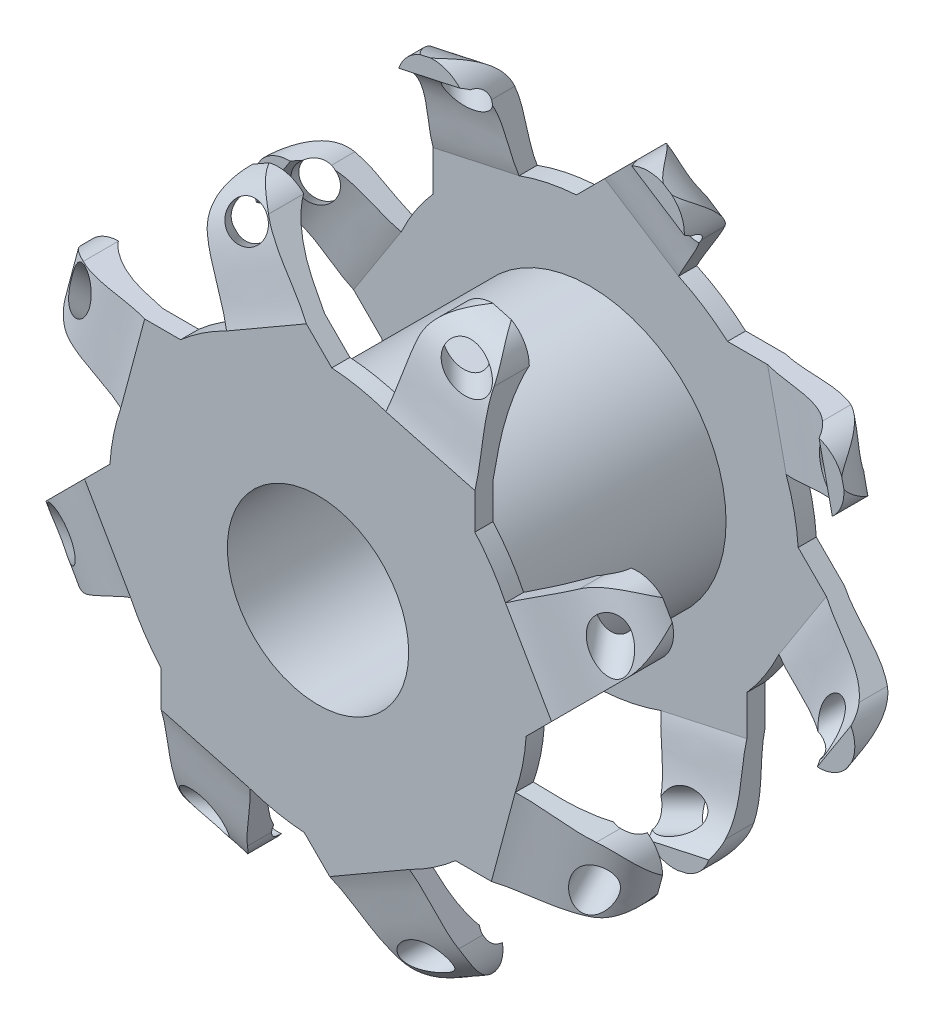
from build123d import *

# Parameters (mm, degrees)
SKETCH1_R               = 15
SS_EXTRUDE1_DEPTH       = 30
SKETCH2_R               = 23
BOSS_EXTRUDE2_DEPTH     = 2
SKETCH3_R               = 23
BOSS_EXTRUDE3_DEPTH     = 2
BOSS_EXTRUDE4_DEPTH     = 6
BOSS_EXTRUDE5_DEPTH     = 6
CUT_EXTRUDE1_START      = -28.577164943
SKETCH8_R               = 2
CUT_EXTRUDE1_DEPTH      = 57.154335489
CUT_EXTRUDE4_DEPTH      = 15
CUT_EXTRUDE5_DEPTH      = 15
CIRPATTERN6_COUNT       = 8
CIRPATTERN7_COUNT       = 8
SKETCH11_R              = 10
CUT_EXTRUDE6_DEPTH      = 3.0000001
CUT_EXTRUDE6_DEPTH_BACK = 31.0000001


with BuildPart() as part:
    # Sketch1 → ss-Extrude1 (new body)
    with BuildSketch(Plane.XY):
        Circle(SKETCH1_R)
    ss_extrude1 = extrude(amount=-SS_EXTRUDE1_DEPTH)

    # Sketch2 → Boss-Extrude2 (add)
    with BuildSketch(Plane.XY):
        Circle(SKETCH2_R)
    boss_extrude2 = extrude(amount=BOSS_EXTRUDE2_DEPTH)

    # Sketch3 → Boss-Extrude3 (add)
    with BuildSketch(Plane(origin=(0, 0, -30), x_dir=(-1, 0, 0), z_dir=(0, 0, -1))):
        Circle(SKETCH3_R)
    extrude(amount=-BOSS_EXTRUDE3_DEPTH)

    # Sketch5 → Boss-Extrude4 (add)
    with BuildSketch(Plane.XY.offset(2)):
        with BuildLine():
            Line((15.154691773, -17.301309698), (28, -17.301309698))
            ThreePointArc((28, -17.301309698), (31.965827804, -13.823047014), (29.034560176, -9.437414611))
            Line((29.034560176, -9.437414611), (21.747532764, -7.486308748))
            ThreePointArc((21.747532764, -7.486308748), (19.092592932, -12.824698638), (15.154691773, -17.301309698))
        make_face()
    boss_extrude4 = extrude(amount=-BOSS_EXTRUDE4_DEPTH)

    # Sketch6 → Boss-Extrude5 (add)
    with BuildSketch(Plane(origin=(0, 0, -30), x_dir=(-1, 0, 0), z_dir=(0, 0, -1))):
        with BuildLine():
            Line((-15.160590445, 17.296141112), (-28, 17.296141112))
            ThreePointArc((-28, 17.296141112), (-31.977210392, 13.722518293), (-28.847895877, 9.387039862))
            Line((-28.847895877, 9.387039862), (-21.629312345, 7.821307274))
            ThreePointArc((-21.629312345, 7.821307274), (-18.995192968, 12.968525133), (-15.160590445, 17.296141112))
        make_face()
    boss_extrude5 = extrude(amount=-BOSS_EXTRUDE5_DEPTH)

    # Sketch8 → Cut-Extrude1 (cut)
    with BuildSketch(Plane(origin=(-1.18e-06, 6.99999764, -6.99999764), x_dir=(0, 0.707106781, 0.707106781), z_dir=(-1.19e-07, 0.707106781, -0.707106781)).offset(CUT_EXTRUDE1_START)):
        with Locations((-10.186742756, 28.331250457)):
            Circle(SKETCH8_R)
    cut_extrude1 = extrude(amount=CUT_EXTRUDE1_DEPTH, mode=Mode.SUBTRACT)

    # Sketch10 → Cut-Extrude4 (cut)
    with BuildSketch(Plane(origin=(-0.648368875, 2.989210877, 0), x_dir=(0.977275312, 0.211973969, 0), z_dir=(0.211973969, -0.977275312, 0))):
        with BuildLine():
            add(Edge.make_bspline(
                [(29.687736426, -26.51649887), (30.951551899, -25.932842362), (31.9870619, -24.948203927), (32.548537045, -23.138080541)],
                knots=[0.618217564, 0.618217564, 0.618217564, 0.618217564, 1, 1, 1, 1], degree=3))
            Line((32.548537045, -23.138080541), (18.65828282, -21.431742028))
            Line((18.65828282, -21.431742028), (17.229503571, -28))
            Line((17.229503571, -28), (22.795706529, -28))
            Line((22.795706529, -28), (22.795706529, -24))
            Line((22.795706529, -24), (27.67778753, -24))
            add(Edge.make_bspline(
                [(27.67778753, -24), (28.093568101, -26.21545958), (29.687736426, -26.51649887)],
                knots=[4.678580772, 4.678580772, 4.678580772, 5.987140113, 5.987140113, 5.987140113], degree=2, weights=[1, 0.75635755, 0.919307532]))
        make_face()
        with BuildLine():
            add(Edge.make_bspline(
                [(22.795706529, -28), (24.996119838, -27.355302034), (27.641249081, -27.461609672), (29.687736426, -26.51649887)],
                knots=[0, 0, 0, 0, 0.618217564, 0.618217564, 0.618217564, 0.618217564], degree=3))
            add(Edge.make_bspline(
                [(27.67778753, -24), (28.093568101, -26.21545958), (29.687736426, -26.51649887)],
                knots=[4.678580772, 4.678580772, 4.678580772, 5.987140113, 5.987140113, 5.987140113], degree=2, weights=[1, 0.75635755, 0.919307532]))
            Line((27.67778753, -24), (22.795706529, -24))
            Line((22.795706529, -24), (22.795706529, -28))
        make_face()
        with BuildLine():
            Line((30.182144557, -30), (30.182144557, -29.090655753))
            add(Edge.make_bspline(
                [(22.795706529, -30), (24.942526902, -29.407717363), (27.910746032, -29.793059948), (30.182144557, -29.090655753)],
                knots=[0, 0, 0, 0, 0.362211893, 0.362211893, 0.362211893, 0.362211893], degree=3))
            Line((22.795706529, -30), (30.182144557, -30))
        make_face()
        with BuildLine():
            add(Edge.make_bspline(
                [(30.182144557, -29.090655753), (30.704087287, -28.929250892), (34.421654826, -27.252327179), (34.897089836, -20.731395195), (34.306434782, -17.906164416)],
                knots=[0.362211893, 0.362211893, 0.362211893, 0.362211893, 0.445444255, 1, 1, 1, 1], degree=3))
            Line((30.182144557, -29.090655753), (30.182144557, -30))
            Line((30.182144557, -30), (22.795706529, -30))
            Line((22.795706529, -30), (17.943893195, -31.941513247))
            Line((17.943893195, -31.941513247), (39.342314041, -33.384330833))
            Line((39.342314041, -33.384330833), (34.306434782, -17.906164416))
        make_face()
    cut_extrude4 = extrude(amount=-CUT_EXTRUDE4_DEPTH, mode=Mode.SUBTRACT)

    # Sketch9 → Cut-Extrude5 (cut)
    with BuildSketch(Plane(origin=(-0.415581547, -1.552121891, 0), x_dir=(0.965973772, -0.258640044, 0), z_dir=(0.258640044, 0.965973772, 0))):
        with BuildLine():
            Line((22.943805474, 4), (22.943805474, 0))
            add(Edge.make_bspline(
                [(22.943805474, 0), (25.095603016, 0.473390819), (27.33894008, 0.923338275), (29.492505686, 2.230659051), (29.678710062, 2.351728443)],
                knots=[0, 0, 0, 0, 0.412137313, 0.451949852, 0.451949852, 0.451949852, 0.451949852], degree=3))
            add(Edge.make_bspline(
                [(28.051525149, 4), (28.639448549, 2.675918332), (29.678710062, 2.351728443)],
                knots=[1.809599306, 1.809599306, 1.809599306, 2.732269736, 2.732269736, 2.732269736], degree=2, weights=[1, 0.852242244, 0.909593483]))
            Line((28.051525149, 4), (22.943805474, 4))
        make_face()
        with BuildLine():
            Line((16.436354412, 0), (22.943805474, 0))
            Line((22.943805474, 0), (22.943805474, 4))
            Line((22.943805474, 4), (28.051525149, 4))
            add(Edge.make_bspline(
                [(28.051525149, 4), (28.639448549, 2.675918332), (29.678710062, 2.351728443)],
                knots=[1.809599306, 1.809599306, 1.809599306, 2.732269736, 2.732269736, 2.732269736], degree=2, weights=[1, 0.852242244, 0.909593483]))
            add(Edge.make_bspline(
                [(29.678710062, 2.351728443), (32.241956104, 4.018341483), (34.141104489, 6.804253018), (28.051525149, 8.762231078)],
                knots=[0.451949852, 0.451949852, 0.451949852, 0.451949852, 1, 1, 1, 1], degree=3))
            Line((28.051525149, 8.762231078), (16.436354412, 6.621068085))
            Line((16.436354412, 6.621068085), (16.436354412, 0))
        make_face()
        with BuildLine():
            add(Edge.make_bspline(
                [(30.487516933, -0.344378274), (32.468941046, 0.375096936), (34.029601794, 1.643169567), (34.391975221, 4.302512453)],
                knots=[0.543111159, 0.543111159, 0.543111159, 0.543111159, 1, 1, 1, 1], degree=3))
            Line((30.487516933, -0.344378274), (30.487516933, -2))
            Line((30.487516933, -2), (22.943805474, -2))
            Line((22.943805474, -2), (19.122740988, -3.480079447))
            Line((19.122740988, -3.480079447), (38.157525495, -7.647167073))
            Line((38.157525495, -7.647167073), (40.071880454, 2.350225744))
            Line((40.071880454, 2.350225744), (35.070824823, 7.847688917))
            Line((35.070824823, 7.847688917), (34.391975221, 4.302512453))
        make_face()
        with BuildLine():
            Line((30.487516933, -2), (30.487516933, -0.344378274))
            add(Edge.make_bspline(
                [(22.943805474, -2), (25.182257071, -1.279688443), (28.13216603, -1.199630098), (30.487516933, -0.344378274)],
                knots=[0, 0, 0, 0, 0.543111159, 0.543111159, 0.543111159, 0.543111159], degree=3))
            Line((22.943805474, -2), (30.487516933, -2))
        make_face()
    cut_extrude5 = extrude(amount=-CUT_EXTRUDE5_DEPTH, mode=Mode.SUBTRACT)

    # CirPattern6: Boss-Extrude2, Boss-Extrude4, Cut-Extrude1, Cut-Extrude5 ×8 about axis
    cirpattern6_axis = Axis((0, 0, 0), (0, 0, -1))
    for i in range(1, CIRPATTERN6_COUNT):
        add(boss_extrude2.rotate(cirpattern6_axis, i * 360 / CIRPATTERN6_COUNT))
        add(boss_extrude4.rotate(cirpattern6_axis, i * 360 / CIRPATTERN6_COUNT))
        add(cut_extrude1.rotate(cirpattern6_axis, i * 360 / CIRPATTERN6_COUNT), mode=Mode.SUBTRACT)
        add(cut_extrude5.rotate(cirpattern6_axis, i * 360 / CIRPATTERN6_COUNT), mode=Mode.SUBTRACT)

    # CirPattern7: ss-Extrude1, Boss-Extrude5, Cut-Extrude1, Cut-Extrude4 ×8 about axis
    cirpattern7_axis = Axis((0, 0, -30), (0, 0, -1))
    for i in range(1, CIRPATTERN7_COUNT):
        add(ss_extrude1.rotate(cirpattern7_axis, i * 360 / CIRPATTERN7_COUNT))
        add(boss_extrude5.rotate(cirpattern7_axis, i * 360 / CIRPATTERN7_COUNT))
        add(cut_extrude1.rotate(cirpattern7_axis, i * 360 / CIRPATTERN7_COUNT), mode=Mode.SUBTRACT)
        add(cut_extrude4.rotate(cirpattern7_axis, i * 360 / CIRPATTERN7_COUNT), mode=Mode.SUBTRACT)

    # Sketch11 → Cut-Extrude6 (cut, two sides)
    with BuildSketch(Plane.XY) as cut_extrude6_sk:
        Circle(SKETCH11_R)
    extrude(amount=CUT_EXTRUDE6_DEPTH, mode=Mode.SUBTRACT)
    extrude(cut_extrude6_sk.sketch, amount=-CUT_EXTRUDE6_DEPTH_BACK, mode=Mode.SUBTRACT)


solid = part.part
